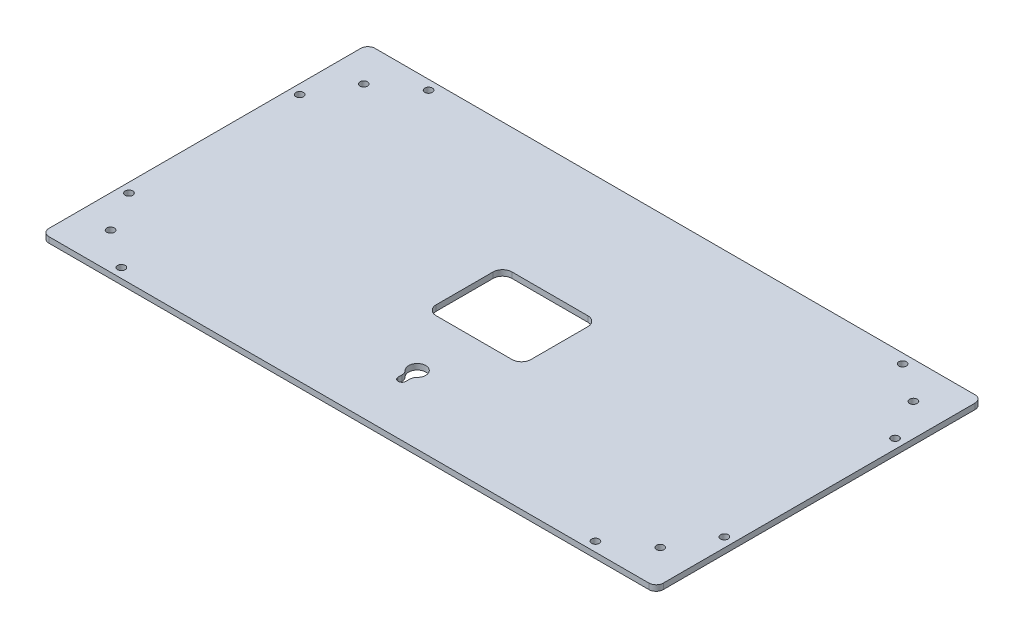
from build123d import *

# Parameters (mm, degrees)
SKETCH_1_R      = 2
EXTRUDE_1_DEPTH = 3


with BuildPart() as part:
    # 草图1 → 凸台-拉伸1 (new body)
    with BuildSketch(Plane.XZ.offset(3)):
        with BuildLine():
            Line((162, -82.2), (162, 82.2))
            ThreePointArc((162, 82.2), (160.887005769, 84.887005769), (158.2, 86))
            Line((158.2, 86), (-158.2, 86))
            ThreePointArc((-158.2, 86), (-160.887005769, 84.887005769), (-162, 82.2))
            Line((-162, 82.2), (-162, -82.2))
            ThreePointArc((-162, -82.2), (-160.887005769, -84.887005769), (-158.2, -86))
            Line((-158.2, -86), (158.2, -86))
            ThreePointArc((158.2, -86), (160.887005769, -84.887005769), (162, -82.2))
        make_face()
        with Locations((-144.95, 66.75)):
            Circle(SKETCH_1_R, mode=Mode.SUBTRACT)
        with Locations((-144.95, -66.75)):
            Circle(SKETCH_1_R, mode=Mode.SUBTRACT)
        with Locations((144.95, -66.75)):
            Circle(SKETCH_1_R, mode=Mode.SUBTRACT)
        with Locations((144.95, 66.75)):
            Circle(SKETCH_1_R, mode=Mode.SUBTRACT)
        with Locations((157, 45)):
            Circle(SKETCH_1_R, mode=Mode.SUBTRACT)
        with Locations((157, -45)):
            Circle(SKETCH_1_R, mode=Mode.SUBTRACT)
        with Locations((125, -81)):
            Circle(SKETCH_1_R, mode=Mode.SUBTRACT)
        with Locations((-125, -81)):
            Circle(SKETCH_1_R, mode=Mode.SUBTRACT)
        with Locations((-157, -45)):
            Circle(SKETCH_1_R, mode=Mode.SUBTRACT)
        with Locations((-157, 45)):
            Circle(SKETCH_1_R, mode=Mode.SUBTRACT)
        with Locations((125, 81)):
            Circle(SKETCH_1_R, mode=Mode.SUBTRACT)
        with Locations((-125, 81)):
            Circle(SKETCH_1_R, mode=Mode.SUBTRACT)
        with BuildLine():
            Line((2, 58), (2, 56))
            ThreePointArc((2, 56), (2.305807419, 54.466070022), (3.176470588, 53.166683629))
            ThreePointArc((3.176470588, 53.166683629), (0, 45.479202711), (-3.176470588, 53.166683629))
            ThreePointArc((-3.176470588, 53.166683629), (-2.305807419, 54.466070022), (-2, 56))
            Line((-2, 56), (-2, 58))
            ThreePointArc((-2, 58), (0, 60), (2, 58))
        make_face(mode=Mode.SUBTRACT)
        with BuildLine():
            Line((25, 15), (25, -15))
            ThreePointArc((25, -15), (23.535533906, -18.535533906), (20, -20))
            Line((20, -20), (-20, -20))
            ThreePointArc((-20, -20), (-23.535533906, -18.535533906), (-25, -15))
            Line((-25, -15), (-25, 15))
            ThreePointArc((-25, 15), (-23.535533906, 18.535533906), (-20, 20))
            Line((-20, 20), (20, 20))
            ThreePointArc((20, 20), (23.535533906, 18.535533906), (25, 15))
        make_face(mode=Mode.SUBTRACT)
    extrude(amount=-EXTRUDE_1_DEPTH)


solid = part.part
